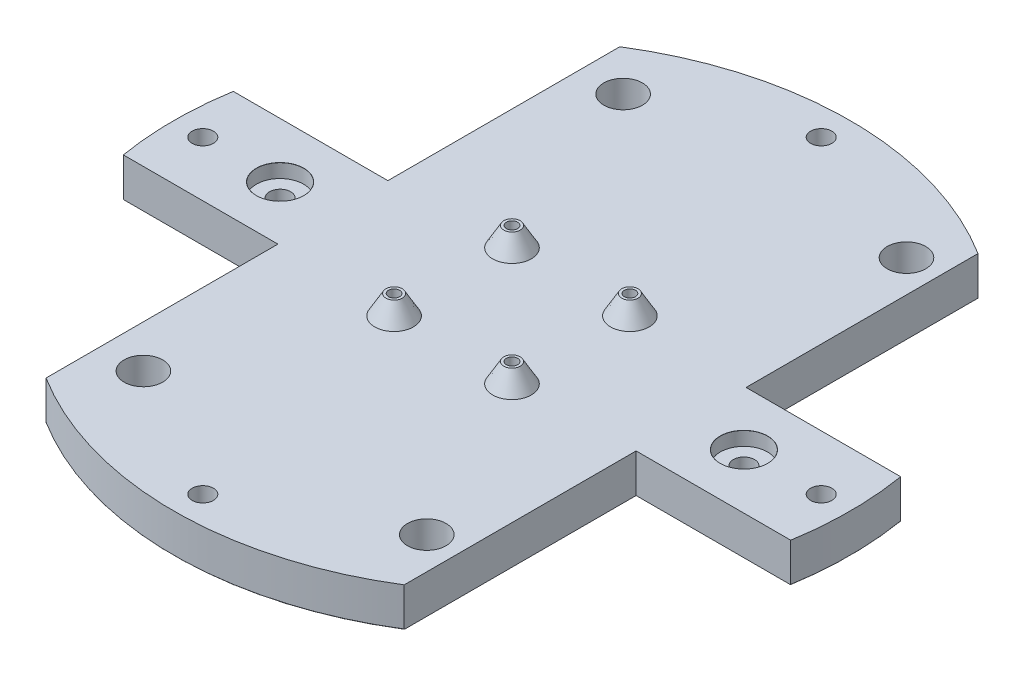
from build123d import *

# Parameters (mm, degrees)
SKETCH1_R                              = 87.5
BOSS_EXTRUDE1_DEPTH                    = 10
SKETCH2_R                              = 7.5
BOSS_EXTRUDE2_DEPTH                    = 80
CBORE_FOR_M5_HEX_HEAD_BOLT1_AT_2_COUNT = 2
CBORE_FOR_M5_HEX_HEAD_BOLT1_AT_2_PITCH = 113.13708499
CBORE_FOR_M5_HEX_HEAD_BOLT1_AT_3_COUNT = 2
CBORE_FOR_M5_HEX_HEAD_BOLT1_AT_3_PITCH = 160
CBORE_FOR_M5_HEX_HEAD_BOLT1_AT_4_COUNT = 2
CBORE_FOR_M5_HEX_HEAD_BOLT1_AT_4_PITCH = 113.13708499
SKETCH5_R                              = 87.5
CUT_EXTRUDE1_DEPTH                     = 80
FILLET1_R                              = 0.1
SKETCH6_R                              = 5
BOSS_EXTRUDE3_DEPTH                    = 5
BOSS_EXTRUDE3_TAPER                    = 30
SKETCH7_R                              = 1.45
CUT_EXTRUDE2_DEPTH                     = 8
SKETCH9_R                              = 5
CUT_EXTRUDE3_DEPTH                     = 10
CUT_EXTRUDE5_DEPTH                     = 10
CBORE_FOR_M5_HEX_HEAD_BOLT2_AT_2_COUNT = 2
CBORE_FOR_M5_HEX_HEAD_BOLT2_AT_2_PITCH = 120


with BuildPart() as part:
    # Sketch1 → Boss-Extrude1 (new body)
    with BuildSketch(Plane(origin=(0, 0, 0), x_dir=(1, 0, 0), z_dir=(0, 1, 0))):
        Circle(SKETCH1_R)
    extrude(amount=BOSS_EXTRUDE1_DEPTH)

    # Sketch2 → Boss-Extrude2 (add)
    with BuildSketch(Plane(origin=(0, 10, 0), x_dir=(1, 0, 0), z_dir=(0, 1, 0))):
        with Locations((0, -80)):
            Circle(SKETCH2_R)
        with Locations((-80, 0)):
            Circle(SKETCH2_R)
        with Locations((0, 80)):
            Circle(SKETCH2_R)
        with Locations((80, 0)):
            Circle(SKETCH2_R)
    extrude(amount=BOSS_EXTRUDE2_DEPTH)

    # Sketch4 → CBORE for M5 Hex Head Bolt1 (revolve, cut)
    with BuildSketch(Plane(origin=(80, 0, 0), x_dir=(0, 0, -1), z_dir=(1, 0, 0))):
        Polygon((0, 0), (0, 21.652366702), (2.75, 20), (2.75, 3.58), (6.12, 3.58), (6.12, 0.025), (6.145, 0), align=None)
    cbore_for_m5_hex_head_bolt1 = revolve(axis=Axis((80, -6.35, 0), (0, 1, 0)), mode=Mode.SUBTRACT)

    # CBORE for M5 Hex Head Bolt1 at 2: CBORE for M5 Hex Head Bolt1 ×2
    with Locations(*[Vector(-0.707106781, 0, -0.707106781) * (i * CBORE_FOR_M5_HEX_HEAD_BOLT1_AT_2_PITCH) for i in range(1, CBORE_FOR_M5_HEX_HEAD_BOLT1_AT_2_COUNT)]):
        add(cbore_for_m5_hex_head_bolt1, mode=Mode.SUBTRACT)

    # CBORE for M5 Hex Head Bolt1 at 3: CBORE for M5 Hex Head Bolt1 ×2
    with Locations(*[(-i * CBORE_FOR_M5_HEX_HEAD_BOLT1_AT_3_PITCH, 0, 0) for i in range(1, CBORE_FOR_M5_HEX_HEAD_BOLT1_AT_3_COUNT)]):
        add(cbore_for_m5_hex_head_bolt1, mode=Mode.SUBTRACT)

    # CBORE for M5 Hex Head Bolt1 at 4: CBORE for M5 Hex Head Bolt1 ×2
    with Locations(*[Vector(-0.707106781, 0, 0.707106781) * (i * CBORE_FOR_M5_HEX_HEAD_BOLT1_AT_4_PITCH) for i in range(1, CBORE_FOR_M5_HEX_HEAD_BOLT1_AT_4_COUNT)]):
        add(cbore_for_m5_hex_head_bolt1, mode=Mode.SUBTRACT)

    # Sketch5 → Cut-Extrude1 (cut)
    with BuildSketch(Plane(origin=(0, 10, 0), x_dir=(1, 0, 0), z_dir=(0, 1, 0))):
        Circle(SKETCH5_R)
    extrude(amount=CUT_EXTRUDE1_DEPTH, mode=Mode.SUBTRACT)

    # Fillet1
    fillet1_edges = [part.edges().sort_by_distance(p)[0] for p in [
        (-87.5, 0, 0),
    ]]
    fillet(fillet1_edges, radius=FILLET1_R)

    # Sketch6 → Boss-Extrude3 (add)
    with BuildSketch(Plane(origin=(0, 10, 0), x_dir=(1, 0, 0), z_dir=(0, 1, 0))):
        with Locations((-15.25, 15.25)):
            Circle(SKETCH6_R)
        with Locations((15.25, 15.25)):
            Circle(SKETCH6_R)
        with Locations((15.25, -15.25)):
            Circle(SKETCH6_R)
        with Locations((-15.25, -15.25)):
            Circle(SKETCH6_R)
    extrude(amount=BOSS_EXTRUDE3_DEPTH, taper=BOSS_EXTRUDE3_TAPER)

    # Sketch7 → Cut-Extrude2 (cut)
    with BuildSketch(Plane(origin=(0, 15, 0), x_dir=(1, 0, 0), z_dir=(0, 1, 0))):
        with Locations((-15.25, 15.25)):
            Circle(SKETCH7_R)
        with Locations((15.25, 15.25)):
            Circle(SKETCH7_R)
        with Locations((15.25, -15.25)):
            Circle(SKETCH7_R)
        with Locations((-15.25, -15.25)):
            Circle(SKETCH7_R)
    extrude(amount=-CUT_EXTRUDE2_DEPTH, mode=Mode.SUBTRACT)

    # Sketch9 → Cut-Extrude3 (cut)
    with BuildSketch(Plane.XZ):
        with Locations((38.003300859, 60.053300859)):
            Circle(SKETCH9_R)
        with Locations((-35.303300859, 60.053300859)):
            Circle(SKETCH9_R)
        with Locations((-35.303300859, -64.053300859)):
            Circle(SKETCH9_R)
        with Locations((38.003300859, -64.053300859)):
            Circle(SKETCH9_R)
    extrude(amount=-CUT_EXTRUDE3_DEPTH, mode=Mode.SUBTRACT)

    # Sketch10 → Cut-Extrude5 (cut)
    with BuildSketch(Plane.XZ):
        with BuildLine():
            Line((-86.336119643, -14.224079762), (-46.336119643, -14.224079762))
            Line((-46.336119643, -14.224079762), (-46.336119643, -74.224079762))
            ThreePointArc((-46.336119643, -74.224079762), (-72.804400755, -48.53626717), (-86.336119643, -14.224079762))
        make_face()
        with BuildLine():
            Line((-46.336119643, 14.224079762), (-46.336119643, 74.224079762))
            ThreePointArc((-46.336119643, 74.224079762), (-72.804400755, 48.53626717), (-86.336119643, 14.224079762))
            Line((-86.336119643, 14.224079762), (-46.336119643, 14.224079762))
        make_face()
        with BuildLine():
            Line((46.336119643, 14.224079762), (86.336119643, 14.224079762))
            ThreePointArc((86.336119643, 14.224079762), (72.804400755, 48.53626717), (46.336119643, 74.224079762))
            Line((46.336119643, 74.224079762), (46.336119643, 14.224079762))
        make_face()
        with BuildLine():
            Line((46.336119643, -14.224079762), (46.336119643, -74.224079762))
            ThreePointArc((46.336119643, -74.224079762), (72.804400755, -48.53626717), (86.336119643, -14.224079762))
            Line((86.336119643, -14.224079762), (46.336119643, -14.224079762))
        make_face()
    extrude(amount=-CUT_EXTRUDE5_DEPTH, mode=Mode.SUBTRACT)

    # Sketch13 → CBORE for M5 Hex Head Bolt2 (revolve, cut)
    with BuildSketch(Plane(origin=(-60, 10, 0), x_dir=(0, 0, 1), z_dir=(1, 0, 0))):
        Polygon((0, 0), (0, 10), (2.75, 10), (2.75, 3.58), (6.12, 3.58), (6.12, 0.025), (6.145, 0), align=None)
    cbore_for_m5_hex_head_bolt2 = revolve(axis=Axis((-60, 16.35, 0), (0, -1, 0)), mode=Mode.SUBTRACT)

    # CBORE for M5 Hex Head Bolt2 at 2: CBORE for M5 Hex Head Bolt2 ×2
    with Locations(*[(i * CBORE_FOR_M5_HEX_HEAD_BOLT2_AT_2_PITCH, 0, 0) for i in range(1, CBORE_FOR_M5_HEX_HEAD_BOLT2_AT_2_COUNT)]):
        add(cbore_for_m5_hex_head_bolt2, mode=Mode.SUBTRACT)


solid = part.part
